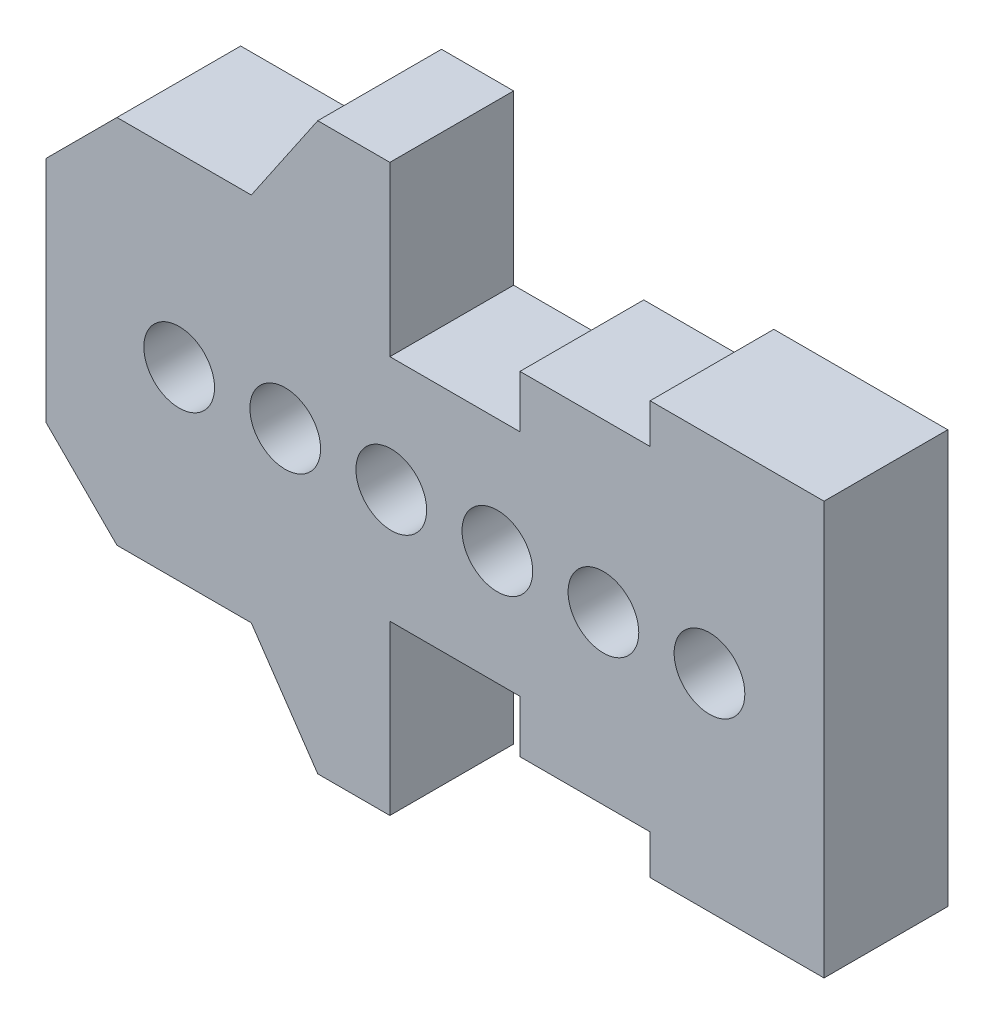
from build123d import *

# Parameters (mm, degrees)
BOSS_EXTRUDE1_DEPTH = 22.225


with BuildPart() as part:
    # Sketch4 → Boss-Extrude1 (new body)
    with BuildSketch(Plane.XY):
        with BuildLine():
            Line((-49.139399536, 0.154397006), (-66.665399536, 0.154397006))
            Line((-66.665399536, 0.154397006), (-66.665399536, -20.419602994))
            Line((-66.665399536, -20.419602994), (-53.965399536, -33.119602994))
            Line((-53.965399536, -33.119602994), (-29.835399536, -33.119602994))
            Line((-29.835399536, -33.119602994), (-17.897399536, -50.645602994))
            Line((-17.897399536, -50.645602994), (-4.943399536, -50.645602994))
            Line((-4.943399536, -50.645602994), (-4.943399536, -20.419602994))
            Line((-4.943399536, -20.419602994), (18.424600464, -20.419602994))
            Line((18.424600464, -20.419602994), (18.424600464, -29.817602994))
            Line((18.424600464, -29.817602994), (41.792600464, -29.817602994))
            Line((41.792600464, -29.817602994), (41.792600464, -36.929602994))
            Line((41.792600464, -36.929602994), (73.034600464, -36.929602994))
            Line((73.034600464, -36.929602994), (73.034600464, 0.154397006))
            Line((73.034600464, 0.154397006), (58.810600464, 0.154397006))
            ThreePointArc((58.810600464, 0.154397006), (52.460600464, -6.195602994), (46.110600464, 0.154397006))
            Line((46.110600464, 0.154397006), (39.760600464, 0.154397006))
            ThreePointArc((39.760600464, 0.154397006), (33.410600464, -6.195602994), (27.060600464, 0.154397006))
            Line((27.060600464, 0.154397006), (20.710600464, 0.154397006))
            ThreePointArc((20.710600464, 0.154397006), (14.360600464, -6.195602994), (8.010600464, 0.154397006))
            Line((8.010600464, 0.154397006), (1.660600464, 0.154397006))
            ThreePointArc((1.660600464, 0.154397006), (-4.689399536, -6.195602994), (-11.039399536, 0.154397006))
            Line((-11.039399536, 0.154397006), (-17.389399536, 0.154397006))
            ThreePointArc((-17.389399536, 0.154397006), (-23.739399536, -6.195602994), (-30.089399536, 0.154397006))
            Line((-30.089399536, 0.154397006), (-36.439399536, 0.154397006))
            ThreePointArc((-36.439399536, 0.154397006), (-42.789399536, -6.195602994), (-49.139399536, 0.154397006))
        make_face()
        with BuildLine():
            Line((-53.965399536, 33.428397006), (-66.665399536, 20.728397006))
            Line((-66.665399536, 20.728397006), (-66.665399536, 0.154397006))
            Line((-66.665399536, 0.154397006), (-49.139399536, 0.154397006))
            ThreePointArc((-49.139399536, 0.154397006), (-42.789399536, 6.504397006), (-36.439399536, 0.154397006))
            Line((-36.439399536, 0.154397006), (-30.089399536, 0.154397006))
            ThreePointArc((-30.089399536, 0.154397006), (-23.739399536, 6.504397006), (-17.389399536, 0.154397006))
            Line((-17.389399536, 0.154397006), (-11.039399536, 0.154397006))
            ThreePointArc((-11.039399536, 0.154397006), (-4.689399536, 6.504397006), (1.660600464, 0.154397006))
            Line((1.660600464, 0.154397006), (8.010600464, 0.154397006))
            ThreePointArc((8.010600464, 0.154397006), (14.360600464, 6.504397006), (20.710600464, 0.154397006))
            Line((20.710600464, 0.154397006), (27.060600464, 0.154397006))
            ThreePointArc((27.060600464, 0.154397006), (33.410600464, 6.504397006), (39.760600464, 0.154397006))
            Line((39.760600464, 0.154397006), (46.110600464, 0.154397006))
            ThreePointArc((46.110600464, 0.154397006), (52.460600464, 6.504397006), (58.810600464, 0.154397006))
            Line((58.810600464, 0.154397006), (73.034600464, 0.154397006))
            Line((73.034600464, 0.154397006), (73.034600464, 37.238397006))
            Line((73.034600464, 37.238397006), (41.792600464, 37.238397006))
            Line((41.792600464, 37.238397006), (41.792600464, 30.126397006))
            Line((41.792600464, 30.126397006), (18.424600464, 30.126397006))
            Line((18.424600464, 30.126397006), (18.424600464, 20.728397006))
            Line((18.424600464, 20.728397006), (-4.943399536, 20.728397006))
            Line((-4.943399536, 20.728397006), (-4.943399536, 50.954397006))
            Line((-4.943399536, 50.954397006), (-17.897399536, 50.954397006))
            Line((-17.897399536, 50.954397006), (-29.835399536, 33.428397006))
            Line((-29.835399536, 33.428397006), (-53.965399536, 33.428397006))
        make_face()
    extrude(amount=BOSS_EXTRUDE1_DEPTH)


solid = part.part
